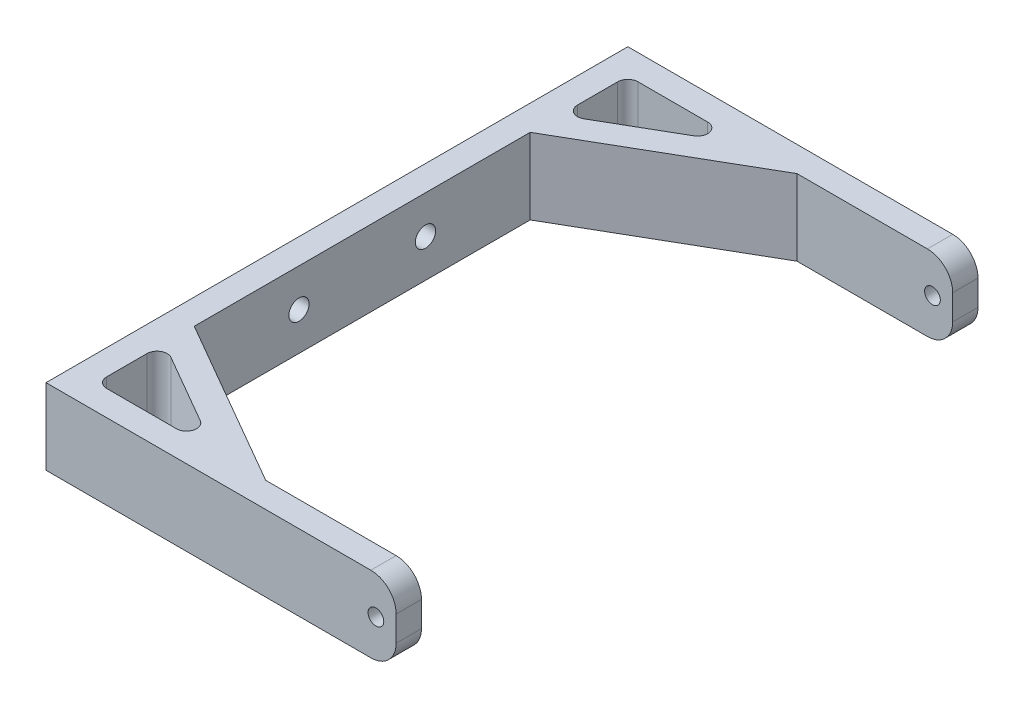
from build123d import *

# Parameters (mm, degrees)
BOSS_EXTRUDE1_DEPTH     = 15
SKETCH2_R               = 1.55
CUT_EXTRUDE1_DEPTH      = 1
CUT_EXTRUDE1_DEPTH_BACK = 116
FILLET1_R               = 2
FILLET2_R               = 5
SKETCH3_R               = 2
CUT_EXTRUDE2_DEPTH      = 6


with BuildPart() as part:
    # Sketch1 → Boss-Extrude1 (new body)
    with BuildSketch(Plane(origin=(0, 0, 0), x_dir=(1, 0, 0), z_dir=(0, 1, 0))):
        Polygon((61.707917854, 52.5), (66.707917854, 52.5), (66.707917854, 57.5), (62.241203502, 57.5), (34.92783027, 57.5), (-2.5, 57.5), (-2.5, 36.198924731), (-2.5, 33.198924731), (-2.5, -33.198924731), (-2.5, -36.198924731), (-2.5, -57.5), (34.92783027, -57.5), (62.241203502, -57.5), (66.707917854, -57.5), (66.707917854, -52.5), (61.707917854, -52.5), (35.930443006, -52.5), (2.5, -33.198924731), (2.5, 33.198924731), (35.930443006, 52.5), align=None)
        Polygon((2.5, 39.085676077), (25.734290584, 52.5), (2.5, 52.5), align=None, mode=Mode.SUBTRACT)
        Polygon((2.5, -52.5), (2.5, -39.085676077), (25.734290584, -52.5), align=None, mode=Mode.SUBTRACT)
    extrude(amount=BOSS_EXTRUDE1_DEPTH)

    # Sketch2 → Cut-Extrude1 (cut, two sides)
    with BuildSketch(Plane.XY.offset(57.5)) as cut_extrude1_sk:
        with Locations((62.707917854, 7.5)):
            Circle(SKETCH2_R)
    extrude(amount=CUT_EXTRUDE1_DEPTH, mode=Mode.SUBTRACT)
    extrude(cut_extrude1_sk.sketch, amount=-CUT_EXTRUDE1_DEPTH_BACK, mode=Mode.SUBTRACT)

    # Fillet1
    fillet1_edges = [part.edges().sort_by_distance(p)[0] for p in [
        (25.734290584, 7.5, -52.5),
        (2.5, 7.5, -52.5),
        (2.5, 7.5, -39.085676077),
        (2.5, 7.5, 52.5),
        (25.734290584, 7.5, 52.5),
        (2.5, 7.5, 39.085676077),
    ]]
    fillet(fillet1_edges, radius=FILLET1_R)

    # Fillet2
    fillet2_edges = [part.edges().sort_by_distance(p)[0] for p in [
        (66.707917854, 15, -55),
        (66.707917854, 0, 55),
        (66.707917854, 0, -55),
        (66.707917854, 15, 55),
    ]]
    fillet(fillet2_edges, radius=FILLET2_R)

    # Sketch3 → Cut-Extrude2 (cut, through all)
    with BuildSketch(Plane(origin=(2.5, 0, 0), x_dir=(0, 0, -1), z_dir=(1, 0, 0))):
        with Locations((-12.5, 7.5)):
            Circle(SKETCH3_R)
        with Locations((12.5, 7.5)):
            Circle(SKETCH3_R)
    extrude(amount=-CUT_EXTRUDE2_DEPTH, mode=Mode.SUBTRACT)


solid = part.part
